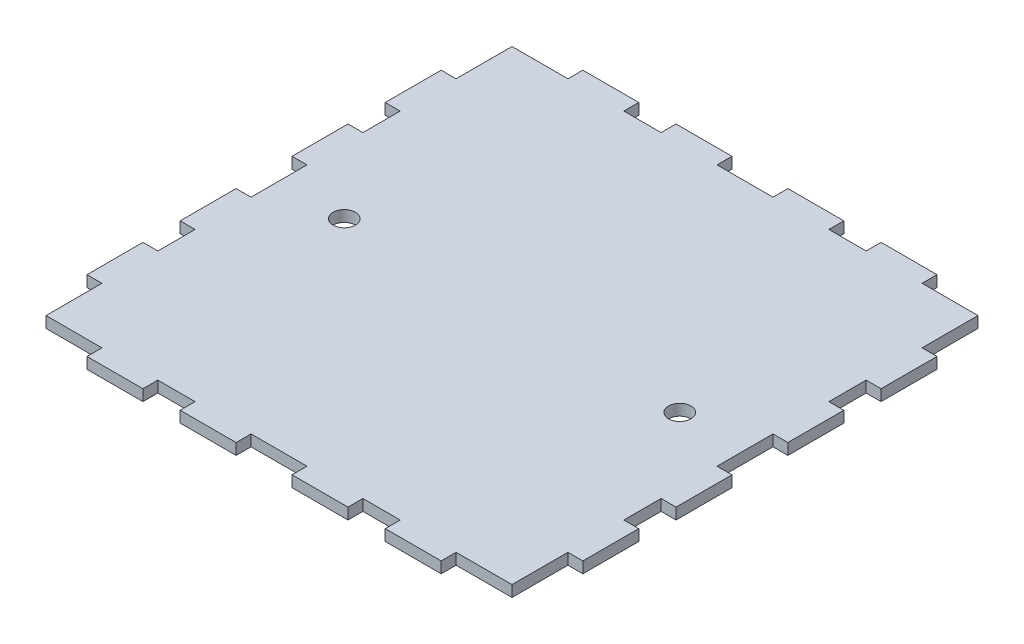
from build123d import *

# Parameters (mm, degrees)
BOSS_EXTRUDE1_DEPTH = 3
SKETCH4_R           = 3
CUT_EXTRUDE2_DEPTH  = 16


with BuildPart() as part:
    # Sketch1 → Boss-Extrude1 (new body)
    with BuildSketch(Plane(origin=(0, 0, 0), x_dir=(1, 0, 0), z_dir=(0, 1, 0))):
        Polygon((7.5, -62.5), (7.5, -66.5), (22.5, -66.5), (22.5, -62.5), (32.5, -62.5), (32.5, -66.5), (47.5, -66.5), (47.5, -62.5), (57.5, -62.5), (62.5, -62.5), (62.5, -59), (62.5, -47.5), (66.5, -47.5), (66.5, -32.5), (62.5, -32.5), (62.5, -22.5), (66.5, -22.5), (66.5, -7.5), (62.5, -7.5), (62.5, 7.5), (66.5, 7.5), (66.5, 22.5), (62.5, 22.5), (62.5, 32.5), (66.5, 32.5), (66.5, 47.5), (62.5, 47.5), (62.5, 59), (62.5, 62.5), (57.5, 62.5), (47.5, 62.5), (47.5, 66.5), (32.5, 66.5), (32.5, 62.5), (22.5, 62.5), (22.5, 66.5), (7.5, 66.5), (7.5, 62.5), (-7.5, 62.5), (-7.5, 66.5), (-22.5, 66.5), (-22.5, 62.5), (-32.5, 62.5), (-32.5, 66.5), (-47.5, 66.5), (-47.5, 62.5), (-59, 62.5), (-62.5, 62.5), (-62.5, 59), (-62.5, 47.5), (-66.5, 47.5), (-66.5, 32.5), (-62.5, 32.5), (-62.5, 22.5), (-66.5, 22.5), (-66.5, 7.5), (-62.5, 7.5), (-62.5, -7.5), (-66.5, -7.5), (-66.5, -22.5), (-62.5, -22.5), (-62.5, -32.5), (-66.5, -32.5), (-66.5, -47.5), (-62.5, -47.5), (-62.5, -59), (-62.5, -62.5), (-59, -62.5), (-47.5, -62.5), (-47.5, -66.5), (-32.5, -66.5), (-32.5, -62.5), (-22.5, -62.5), (-22.5, -66.5), (-7.5, -66.5), (-7.5, -62.5), align=None)
    extrude(amount=BOSS_EXTRUDE1_DEPTH)

    # Sketch4 → Cut-Extrude2 (cut)
    with BuildSketch(Plane(origin=(0, 0, 0), x_dir=(1, 0, 0), z_dir=(0, 1, 0))):
        with Locations((-45, 0)):
            Circle(SKETCH4_R)
        with Locations((45, 0)):
            Circle(SKETCH4_R)
    extrude(amount=CUT_EXTRUDE2_DEPTH, mode=Mode.SUBTRACT)


solid = part.part
